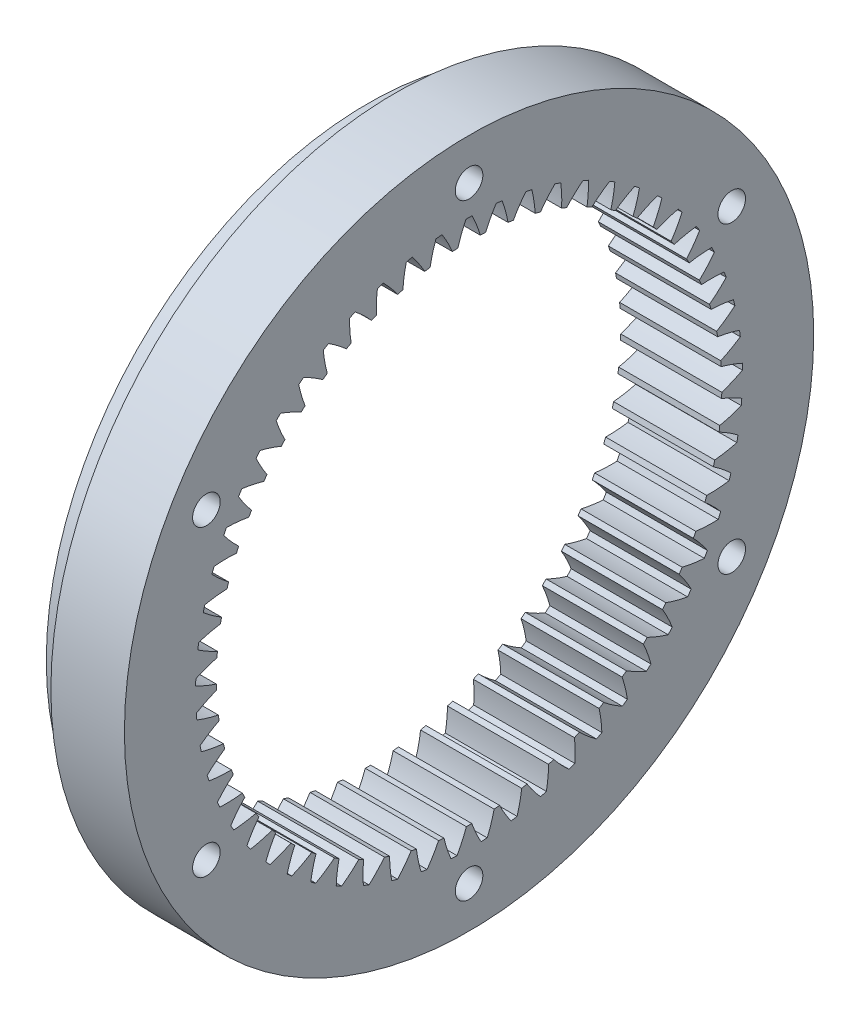
from build123d import *

# Parameters (mm, degrees)
BASPROSKE_W         = 11
BASPROSKE_H         = 7.5
TOOTHCUT_DEPTH      = 51.705029336
TEETHCUTS_COUNT     = 57
TEETHCUTS_ANGLE     = 353.684210526
SKETCH1_R           = 37.5
SKETCH1_R_2         = 35
BOSS_EXTRUDE1_DEPTH = 8
SKETCH2_R           = 1.5
CUT_EXTRUDE1_DEPTH  = 55.161794653


with BuildPart() as part:
    # BasProSke → Base-Revolve (revolve)
    with BuildSketch(Plane(origin=(0, 0, 0), x_dir=(1, 0, 0), z_dir=(0, 1, 0))):
        with Locations((5.5, 31.25)):
            Rectangle(BASPROSKE_W, BASPROSKE_H)
    revolve(axis=Axis((-10, 0, 0), (1, 0, 0)))

    # TooCutSke → ToothCut (cut, through all)
    with BuildSketch(Plane(origin=(0, 0, 0), x_dir=(0, 0, -1), z_dir=(1, 0, 0))):
        with BuildLine():
            ThreePointArc((1.227657204, 27.447158377), (0.830028238, 28.617582186), (0.332461862, 29.749142342))
            ThreePointArc((0.332461862, 29.749142342), (0, 29.751), (-0.332461862, 29.749142342))
            ThreePointArc((-0.332461862, 29.749142342), (-0.830028238, 28.617582186), (-1.227657204, 27.447158377))
            ThreePointArc((-1.227657204, 27.447158377), (0, 27.4746), (1.227657204, 27.447158377))
        make_face()
    toothcut = extrude(amount=TOOTHCUT_DEPTH, mode=Mode.SUBTRACT)

    # TeethCuts: ToothCut ×57 about axis
    teethcuts_axis = Axis((-10, 0, 0), (1, 0, 0))
    for i in range(1, TEETHCUTS_COUNT):
        add(toothcut.rotate(teethcuts_axis, i * TEETHCUTS_ANGLE / (TEETHCUTS_COUNT - 1)), mode=Mode.SUBTRACT)

    # Sketch1 → Boss-Extrude1 (add)
    with BuildSketch(Plane(origin=(11, 0, 0), x_dir=(0, 0, -1), z_dir=(1, 0, 0))):
        Circle(SKETCH1_R)
        Circle(SKETCH1_R_2, mode=Mode.SUBTRACT)
    extrude(amount=-BOSS_EXTRUDE1_DEPTH)

    # Sketch2 → Cut-Extrude1 (cut, through all)
    with BuildSketch(Plane.ZY):
        with Locations((28.578838325, 16.5)):
            Circle(SKETCH2_R)
        with Locations((28.578838325, -16.5)):
            Circle(SKETCH2_R)
        with Locations((0, -33)):
            Circle(SKETCH2_R)
        with Locations((-28.578838325, -16.5)):
            Circle(SKETCH2_R)
        with Locations((-28.578838325, 16.5)):
            Circle(SKETCH2_R)
        with Locations((0, 33)):
            Circle(SKETCH2_R)
    extrude(amount=-CUT_EXTRUDE1_DEPTH, mode=Mode.SUBTRACT)


solid = part.part
